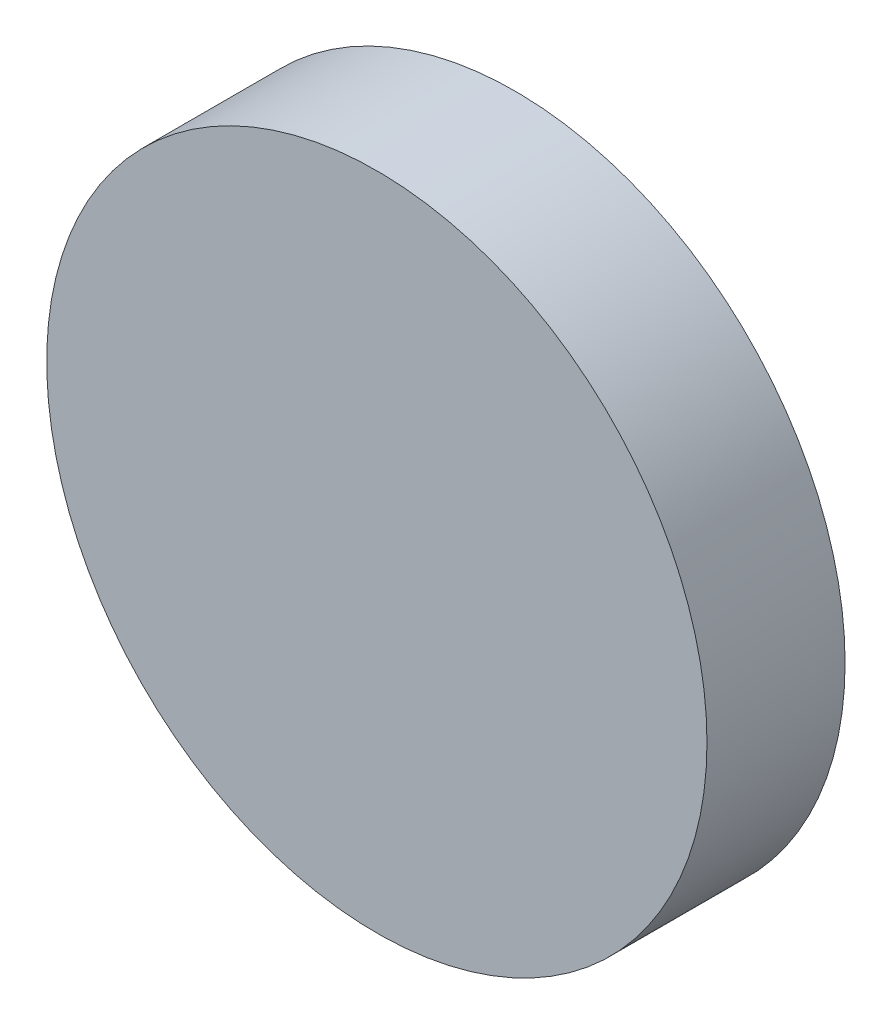
from build123d import *

# Parameters (mm, degrees)
SKETCH1_R           = 45.53585
BOSS_EXTRUDE1_DEPTH = 19.05


with BuildPart() as part:
    # Sketch1 → Boss-Extrude1 (new body)
    with BuildSketch(Plane.XY):
        Circle(SKETCH1_R)
    extrude(amount=BOSS_EXTRUDE1_DEPTH)


solid = part.part
